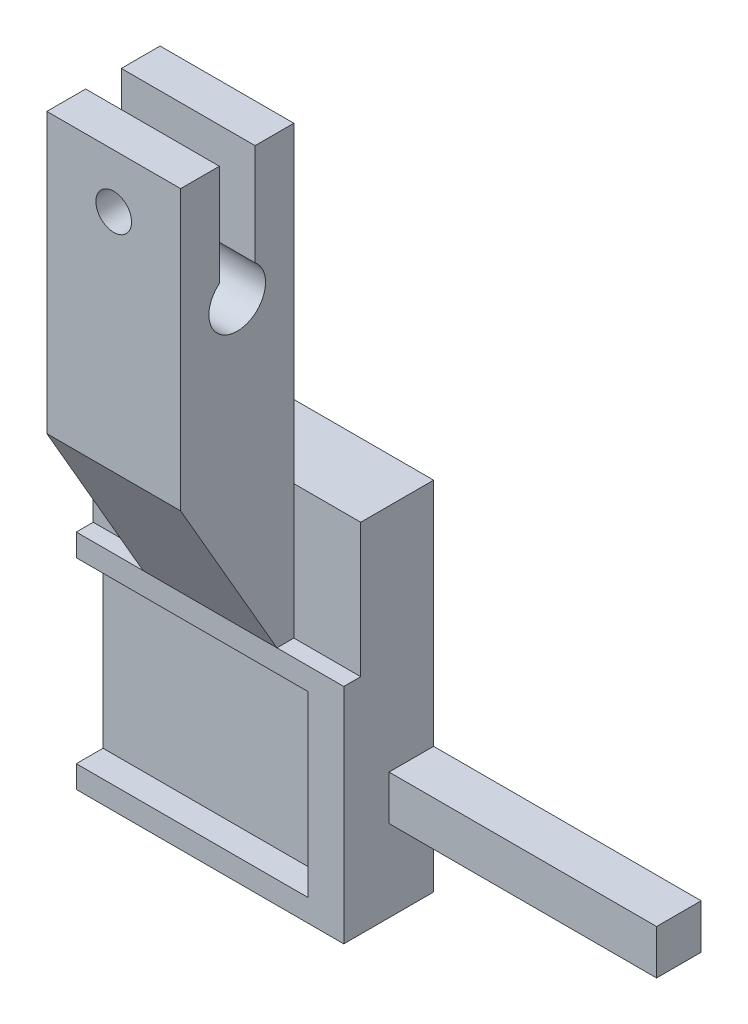
from build123d import *

# Parameters (mm, degrees)
BOSS_EXTRUDE1_DEPTH      = 15
CUT_EXTRUDE4_DEPTH       = 16
SKETCH8_R                = 2
CUT_EXTRUDE5_DEPTH       = 21.875
SKETCH9_W                = 8.175
SKETCH9_H                = 40
BOSS_EXTRUDE2_DEPTH      = 22.5
BOSS_EXTRUDE2_DEPTH_BACK = 7.5
SKETCH11_W               = 1.1
SKETCH11_H               = 20
CUT_EXTRUDE6_DEPTH       = 26
BOSS_EXTRUDE4_DEPTH      = 30
SKETCH13_W               = 1.9
SKETCH13_H               = 25
BOSS_EXTRUDE5_DEPTH      = 4
SKETCH15_W               = 5
SKETCH15_H               = 5
BOSS_EXTRUDE6_DEPTH      = 30
CUT_EXTRUDE7_DEPTH       = 23.5


with BuildPart() as part:
    # Sketch2 → Boss-Extrude1 (new body)
    with BuildSketch(Plane(origin=(0, 0, 0), x_dir=(0, 0, -1), z_dir=(1, 0, 0))):
        Polygon((0, 0), (0, 40), (-8.175, 40), (-8.175, 75), (-20.875, 75), (-20.875, 25), (-8.175, 25), (-8.175, 0), align=None)
    extrude(amount=BOSS_EXTRUDE1_DEPTH)

    # Sketch7 → Cut-Extrude4 (cut, through all)
    with BuildSketch(Plane.ZY):
        with BuildLine():
            Line((12.525, 75), (12.525, 63.615892333))
            ThreePointArc((12.525, 63.615892333), (14.525, 57.975), (16.525, 63.615892333))
            Line((16.525, 63.615892333), (16.525, 75))
            Line((16.525, 75), (12.525, 75))
        make_face()
    extrude(amount=-CUT_EXTRUDE4_DEPTH, mode=Mode.SUBTRACT)

    # Sketch8 → Cut-Extrude5 (cut, through all)
    with BuildSketch(Plane.XY.offset(20.875)):
        with Locations((7.5, 69)):
            Circle(SKETCH8_R)
    extrude(amount=-CUT_EXTRUDE5_DEPTH, mode=Mode.SUBTRACT)

    # Sketch9 → Boss-Extrude2 (add, two sides)
    with BuildSketch(Plane(origin=(0, 0, 0), x_dir=(0, 0, -1), z_dir=(1, 0, 0))) as boss_extrude2_sk:
        with Locations((-4.0875, 20)):
            Rectangle(SKETCH9_W, SKETCH9_H)
    extrude(amount=BOSS_EXTRUDE2_DEPTH)
    extrude(boss_extrude2_sk.sketch, amount=-BOSS_EXTRUDE2_DEPTH_BACK)

    # Sketch11 → Cut-Extrude6 (cut)
    with BuildSketch(Plane.ZY.offset(7.5)):
        with Locations((7.625, 12.5)):
            Rectangle(SKETCH11_W, SKETCH11_H)
    extrude(amount=-CUT_EXTRUDE6_DEPTH, mode=Mode.SUBTRACT)

    # Sketch12 → Boss-Extrude4 (add, through all)
    with BuildSketch(Plane.ZY.offset(7.5)):
        Polygon((10.075, 22.5), (7.075, 22.5), (7.075, 2.5), (10.075, 2.5), (10.075, 0), (5.075, 0), (5.075, 25), (10.075, 25), align=None)
    extrude(amount=-BOSS_EXTRUDE4_DEPTH)

    # Sketch13 → Boss-Extrude5 (add)
    with BuildSketch(Plane(origin=(22.5, 0, 0), x_dir=(0, 0, -1), z_dir=(1, 0, 0))):
        with Locations((-9.125, 12.5)):
            Rectangle(SKETCH13_W, SKETCH13_H)
    extrude(amount=-BOSS_EXTRUDE5_DEPTH)

    # Sketch15 → Boss-Extrude6 (add)
    with BuildSketch(Plane(origin=(22.5, 0, 0), x_dir=(0, 0, -1), z_dir=(1, 0, 0))):
        with Locations((-2.5, 11.65)):
            Rectangle(SKETCH15_W, SKETCH15_H)
    extrude(amount=BOSS_EXTRUDE6_DEPTH)

    # Sketch16 → Cut-Extrude7 (cut, through all)
    with BuildSketch(Plane(origin=(15, 0, 0), x_dir=(0, 0, -1), z_dir=(1, 0, 0))):
        Polygon((-10.075, 25), (-20.875, 43.706148722), (-20.875, 25), align=None)
    extrude(amount=-CUT_EXTRUDE7_DEPTH, mode=Mode.SUBTRACT)


solid = part.part
